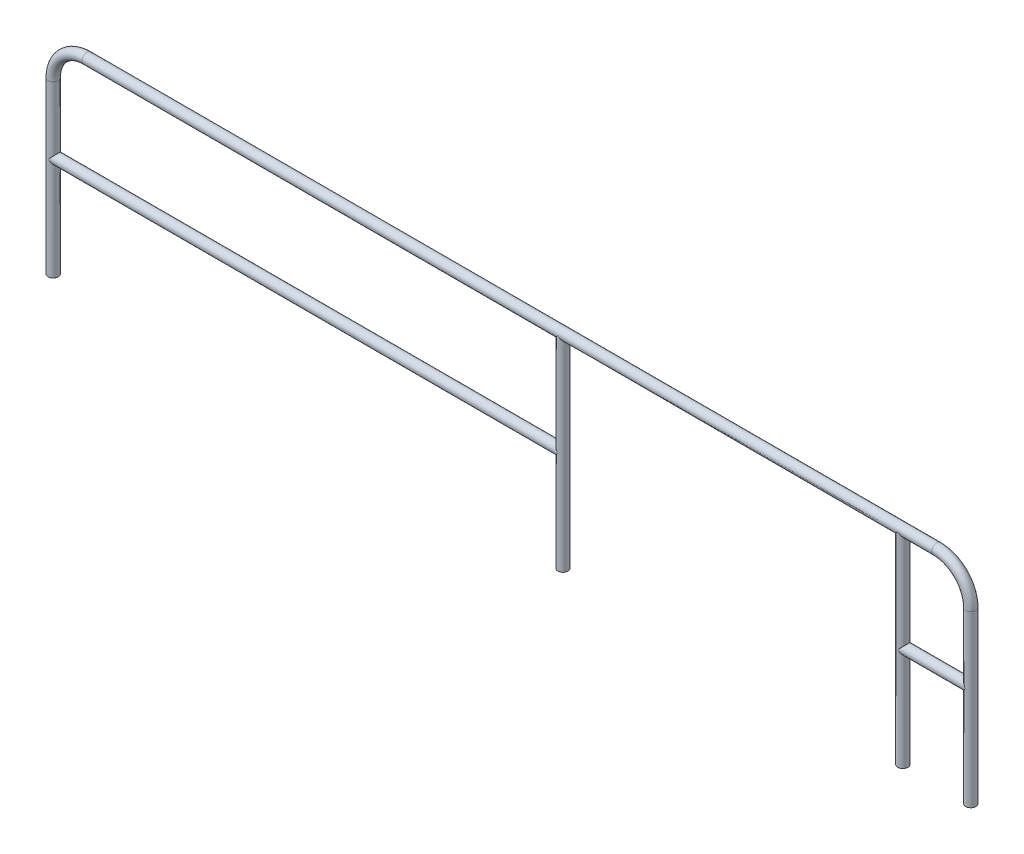
from build123d import *

# Parameters (mm, degrees)
SKETCH_2_R       = 0.75
SKETCH_13_R      = 0.75
EXTRUDE_7_DEPTH  = 30
SKETCH_14_R      = 0.75
EXTRUDE_8_DEPTH  = 30
SKETCH_15_R      = 0.75
EXTRUDE_9_DEPTH  = 75
SKETCH_17_R      = 0.75
EXTRUDE_10_DEPTH = 10


with BuildPart() as part:
    # 扫描1: sweep along a path in 草图1
    with BuildLine(Plane.XY) as sweep_1_path:
        Line((50, 0), (50, 25))
        ThreePointArc((50, 25), (48.535533906, 28.535533906), (45, 30))
        Line((45, 30), (-80, 30))
        ThreePointArc((-80, 30), (-83.535533906, 28.535533906), (-85, 25))
        Line((-85, 25), (-85, 0))
    # 草图2 → 扫描1 (sweep)
    with BuildSketch(Plane(origin=(0, 0, 0), x_dir=(1, 0, 0), z_dir=(0, 1, 0))):
        with Locations((-85, 0)):
            Circle(SKETCH_2_R)
    sweep(path=sweep_1_path.line)

    # 草图13 → 凸台-拉伸7 (add)
    with BuildSketch(Plane(origin=(0, 0, 0), x_dir=(1, 0, 0), z_dir=(0, 1, 0))):
        with Locations((40, 0)):
            Circle(SKETCH_13_R)
    extrude(amount=EXTRUDE_7_DEPTH)

    # 草图14 → 凸台-拉伸8 (add)
    with BuildSketch(Plane(origin=(0, 0, 0), x_dir=(-1, 0, 0), z_dir=(0, 1, 0))):
        with Locations((10, 0)):
            Circle(SKETCH_14_R)
    extrude(amount=EXTRUDE_8_DEPTH)

    # 草图15 → 凸台-拉伸9 (add)
    with BuildSketch(Plane(origin=(-85, 0, 0), x_dir=(0, 0, -1), z_dir=(1, 0, 0))):
        with Locations((0, 15)):
            Circle(SKETCH_15_R)
    extrude(amount=EXTRUDE_9_DEPTH)

    # 草图17 → 凸台-拉伸10 (add)
    with BuildSketch(Plane(origin=(50, 15, 0), x_dir=(0, 0, 1), z_dir=(-1, 0, 0))):
        Circle(SKETCH_17_R)
    extrude(amount=EXTRUDE_10_DEPTH)


solid = part.part
